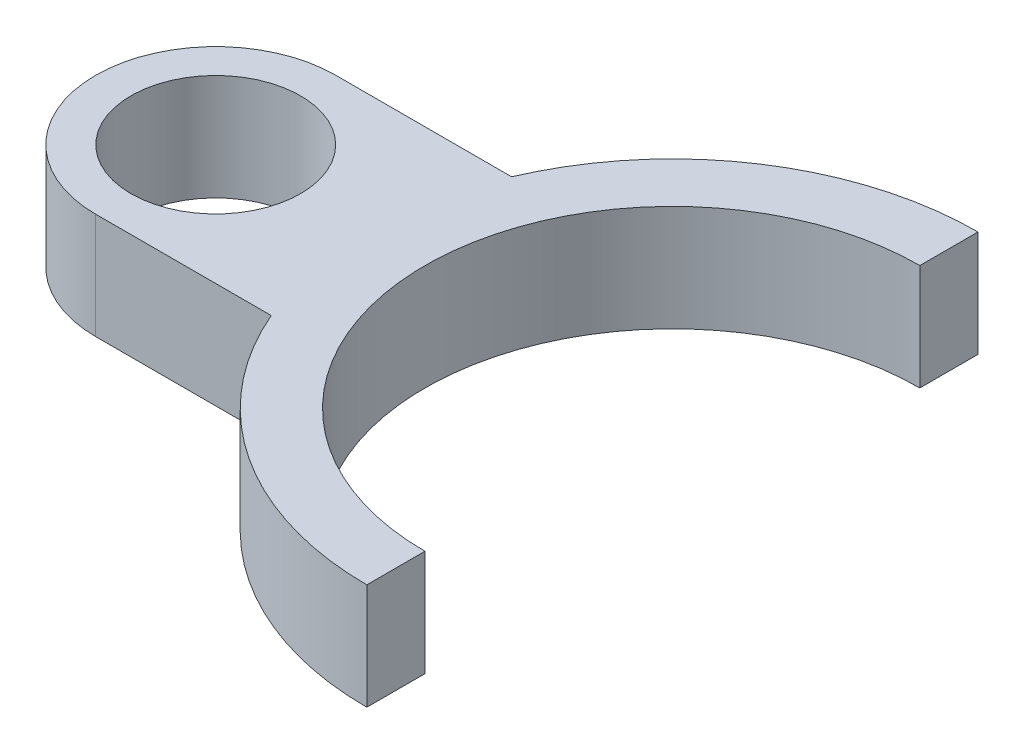
from build123d import *

# Parameters (mm, degrees)
SKETCH1_R           = 17.000673514
SKETCH1_R_2         = 12
BOSS_EXTRUDE1_DEPTH = 15
BOSS_EXTRUDE2_DEPTH = 15
BOSS_EXTRUDE3_DEPTH = 15


with BuildPart() as part:
    # Sketch1 → Boss-Extrude1 (new body)
    with BuildSketch(Plane(origin=(0, 0, 0), x_dir=(1, 0, 0), z_dir=(0, 1, 0))):
        Circle(SKETCH1_R)
        Circle(SKETCH1_R_2, mode=Mode.SUBTRACT)
    extrude(amount=BOSS_EXTRUDE1_DEPTH)

    # Sketch2 → Boss-Extrude2 (add)
    with BuildSketch(Plane(origin=(0, 15, 0), x_dir=(1, 0, 0), z_dir=(0, 1, 0))):
        with BuildLine():
            Line((0, 17.000673514), (25, 17.000673514))
            Line((25, 17.000673514), (25, -17.000673514))
            Line((25, -17.000673514), (0, -17.000673514))
            ThreePointArc((0, -17.000673514), (17.000673514, 0), (0, 17.000673514))
        make_face()
    extrude(amount=-BOSS_EXTRUDE2_DEPTH)

    # Sketch3 → Boss-Extrude3 (add)
    with BuildSketch(Plane(origin=(0, 0, 0), x_dir=(-1, 0, 0), z_dir=(0, -1, 0))):
        with BuildLine():
            ThreePointArc((-29.598035728, 0), (-39.849298386, -24.748737342), (-64.598035728, -35))
            Line((-64.598035728, -35), (-64.598035728, -43.228194221))
            ThreePointArc((-64.598035728, -43.228194221), (-34.031086456, -30.566949272), (-21.369841507, 0))
            ThreePointArc((-21.369841507, 0), (-34.031086456, 30.566949272), (-64.598035728, 43.228194221))
            Line((-64.598035728, 43.228194221), (-64.598035728, 35))
            ThreePointArc((-64.598035728, 35), (-39.849298386, 24.748737342), (-29.598035728, 0))
        make_face()
    extrude(amount=-BOSS_EXTRUDE3_DEPTH)


solid = part.part
